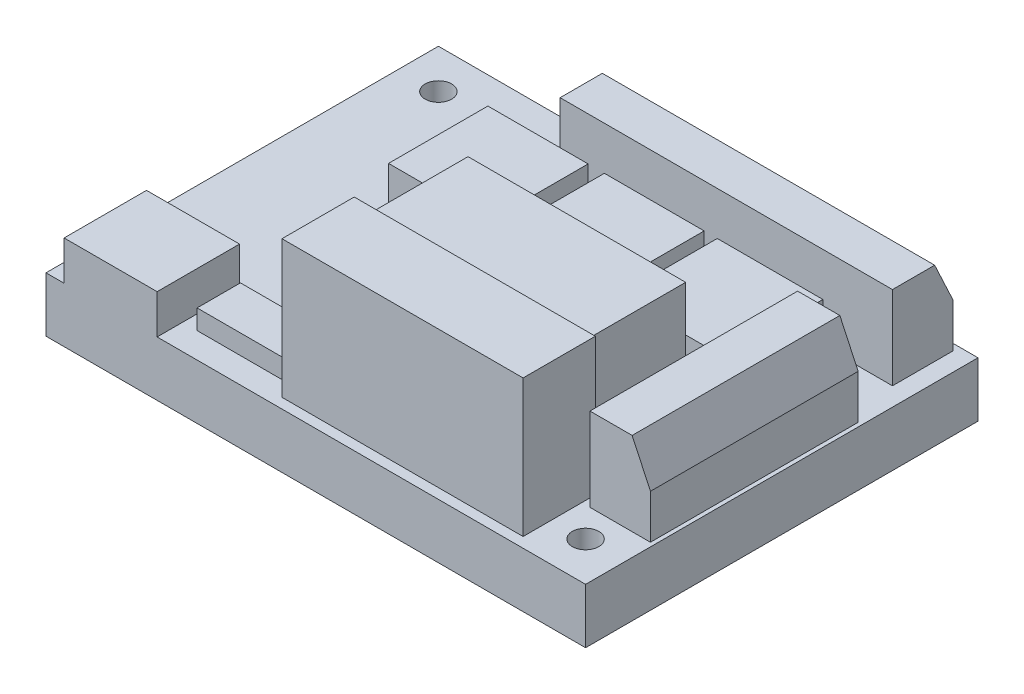
from build123d import *

# Parameters (mm, degrees)
SKIZZE1_W                       = 55
SKIZZE1_H                       = 40
SKIZZE1_R                       = 1.35
AUFSATZ_LINEAR_AUSTRAGEN1_DEPTH = 5.6
SKIZZE2_W                       = 33.875763277
SKIZZE2_H                       = 6.167598205
SKIZZE2_W_2                     = 6.167598205
SKIZZE2_H_2                     = 21.172352048
AUFSATZ_LINEAR_AUSTRAGEN2_DEPTH = 8.5
SKIZZE2_3_W                     = 9.48153157
SKIZZE2_3_H                     = 8.400032762
AUFSATZ_LINEAR_AUSTRAGEN3_DEPTH = 4
SKIZZE2_4_W                     = 10.217961205
SKIZZE2_4_H                     = 10.125907501
SKIZZE2_4_W_2                   = 10.171934354
SKIZZE2_4_W_3                   = 10.770283433
AUFSATZ_LINEAR_AUSTRAGEN4_DEPTH = 5
SKIZZE2_5_W                     = 22.184942798
SKIZZE2_5_H                     = 9.573585274
AUFSATZ_LINEAR_AUSTRAGEN5_DEPTH = 12.5
SKIZZE2_6_W                     = 24.578339117
SKIZZE2_6_H                     = 7.364296365
AUFSATZ_LINEAR_AUSTRAGEN6_DEPTH = 14
SKIZZE2_7_W                     = 9.113316751
SKIZZE2_7_H                     = 4.418577819
AUFSATZ_LINEAR_AUSTRAGEN7_DEPTH = 2
FASE1_SIZE                      = 4
FASE1_SIZE2                     = 1.865230633
FASE1_PART_2_SIZE               = 4
FASE1_PART_2_SIZE2              = 1.865230633


with BuildPart() as part:
    # Skizze1 → Aufsatz-Linear austragen1 (new body)
    with BuildSketch(Plane(origin=(0, 0, 0), x_dir=(1, 0, 0), z_dir=(0, 1, 0))):
        Rectangle(SKIZZE1_W, SKIZZE1_H)
        with Locations((-23.5, 16)):
            Circle(SKIZZE1_R, mode=Mode.SUBTRACT)
        with Locations((23.5, -16)):
            Circle(SKIZZE1_R, mode=Mode.SUBTRACT)
    extrude(amount=AUFSATZ_LINEAR_AUSTRAGEN1_DEPTH)

    # Skizze2 → Aufsatz-Linear austragen2 (add)
    with BuildSketch(Plane(origin=(0, 5.6, 0), x_dir=(1, 0, 0), z_dir=(0, 1, 0))):
        with Locations((8.681351592, 16.246278391)):
            Rectangle(SKIZZE2_W, SKIZZE2_H)
        with Locations((24.008293401, -2.394596782)):
            Rectangle(SKIZZE2_W_2, SKIZZE2_H_2)
    extrude(amount=AUFSATZ_LINEAR_AUSTRAGEN2_DEPTH)

    # Skizze2_3 → Aufsatz-Linear austragen3 (add)
    with BuildSketch(Plane(origin=(0, 5.6, 0), x_dir=(1, 0, 0), z_dir=(0, 1, 0))):
        with Locations((-20.913914423, -15.799983619)):
            Rectangle(SKIZZE2_3_W, SKIZZE2_3_H)
    extrude(amount=AUFSATZ_LINEAR_AUSTRAGEN3_DEPTH)

    # Skizze2_4 → Aufsatz-Linear austragen4 (add)
    with BuildSketch(Plane(origin=(0, 5.6, 0), x_dir=(1, 0, 0), z_dir=(0, 1, 0))):
        with Locations((-9.591308763, 7.178988492)):
            Rectangle(SKIZZE2_4_W, SKIZZE2_4_H)
        with Locations((2.260605699, 7.178988492)):
            Rectangle(SKIZZE2_4_W_2, SKIZZE2_4_H)
        with Locations((14.066493309, 7.178988492)):
            Rectangle(SKIZZE2_4_W_3, SKIZZE2_4_H)
    extrude(amount=AUFSATZ_LINEAR_AUSTRAGEN4_DEPTH)

    # Skizze2_5 → Aufsatz-Linear austragen5 (add)
    with BuildSketch(Plane(origin=(0, 5.6, 0), x_dir=(1, 0, 0), z_dir=(0, 1, 0))):
        with Locations((7.346572876, -5.524422737)):
            Rectangle(SKIZZE2_5_W, SKIZZE2_5_H)
    extrude(amount=AUFSATZ_LINEAR_AUSTRAGEN5_DEPTH)

    # Skizze2_6 → Aufsatz-Linear austragen6 (add)
    with BuildSketch(Plane(origin=(0, 5.6, 0), x_dir=(1, 0, 0), z_dir=(0, 1, 0))):
        with Locations((7.806841398, -15.282115421)):
            Rectangle(SKIZZE2_6_W, SKIZZE2_6_H)
    extrude(amount=AUFSATZ_LINEAR_AUSTRAGEN6_DEPTH)

    # Skizze2_7 → Aufsatz-Linear austragen7 (add)
    with BuildSketch(Plane(origin=(0, 5.6, 0), x_dir=(1, 0, 0), z_dir=(0, 1, 0))):
        with Locations((-10.14363099, -15.190061716)):
            Rectangle(SKIZZE2_7_W, SKIZZE2_7_H)
    extrude(amount=AUFSATZ_LINEAR_AUSTRAGEN7_DEPTH)

    # Fase1
    fase1_edges = [part.edges().sort_by_distance(p)[0] for p in [
        (8.681351592, 14.1, -19.330077493),
    ]]
    fase1_side = [part.faces().sort_by_distance(p)[0] for p in [
        (8.681351592, 9.85, -19.330077493),
    ]]
    chamfer(fase1_edges, length=FASE1_SIZE, length2=FASE1_SIZE2, reference=fase1_side[0])

    # Fase1 part 2
    fase1_part_2_edges = [part.edges().sort_by_distance(p)[0] for p in [
        (27.092092503, 14.1, 2.394596782),
    ]]
    fase1_part_2_side = [part.faces().sort_by_distance(p)[0] for p in [
        (27.092092503, 9.85, 2.394596782),
    ]]
    chamfer(fase1_part_2_edges, length=FASE1_PART_2_SIZE, length2=FASE1_PART_2_SIZE2, reference=fase1_part_2_side[0])


solid = part.part
